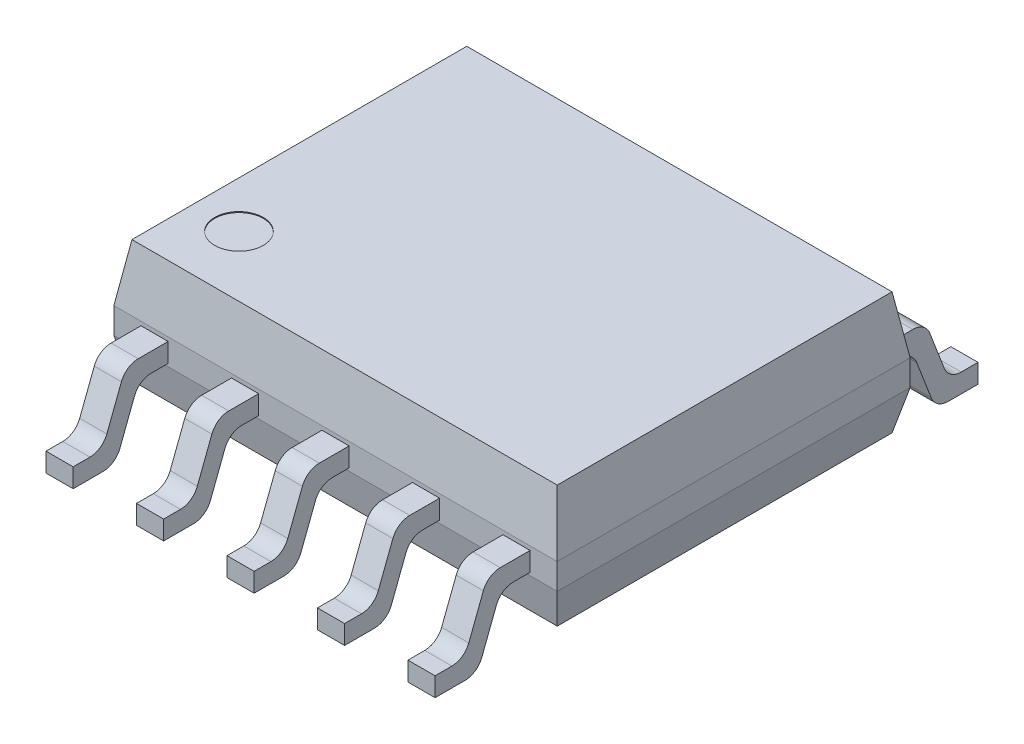
from build123d import *

# Parameters (mm, degrees)
SKETCH1_W           = 4.9
SKETCH1_H           = 3.9
BOSS_EXTRUDE1_DEPTH = 1.35
BOSS_EXTRUDE2_DEPTH = 4.9
FILLET1_R           = 0.2
SKETCH3_OUTSIDE_W   = 8.328
SKETCH3_OUTSIDE_H   = 8.378
SKETCH3_OUTSIDE_W_2 = 0.3
SKETCH3_OUTSIDE_H_2 = 1.05
CUT_EXTRUDE1_DEPTH  = 2.56
CHAMFER1_SIZE       = 0.1
CHAMFER1_SIZE2      = 0.433147587
CHAMFER2_SIZE       = 0.1
CHAMFER2_SIZE2      = 0.631375151
SKETCH4_R           = 0.268615899
CUT_EXTRUDE2_DEPTH  = 0.01


with BuildPart() as part:
    # Sketch1 → Boss-Extrude1 (new body)
    with BuildSketch(Plane(origin=(0, 0, 0), x_dir=(1, 0, 0), z_dir=(0, 1, 0))):
        Rectangle(SKETCH1_W, SKETCH1_H)
    extrude(amount=BOSS_EXTRUDE1_DEPTH)

    # Chamfer1
    chamfer1_edges = [part.edges().sort_by_distance(p)[0] for p in [
        (0, 0, -1.95),
        (2.45, 0, 0),
        (0, 0, 1.95),
        (-2.45, 0, 0),
    ]]
    chamfer1_side = [part.faces().sort_by_distance(p)[0] for p in [
        (0, 0, 0),
    ]]
    chamfer(chamfer1_edges, length=CHAMFER1_SIZE, length2=CHAMFER1_SIZE2, reference=chamfer1_side[0])

    # Chamfer2
    chamfer2_edges = [part.edges().sort_by_distance(p)[0] for p in [
        (2.45, 1.35, 0),
        (0, 1.35, -1.95),
        (-2.45, 1.35, 0),
        (0, 1.35, 1.95),
    ]]
    chamfer2_side = [part.faces().sort_by_distance(p)[0] for p in [
        (0, 1.35, 0),
    ]]
    chamfer(chamfer2_edges, length=CHAMFER2_SIZE, length2=CHAMFER2_SIZE2, reference=chamfer2_side[0])

    # Sketch4 → Cut-Extrude2 (cut)
    with BuildSketch(Plane(origin=(0, 1.35, 0), x_dir=(1, 0, 0), z_dir=(0, 1, 0))):
        with Locations((-1.836838836, -1.180555556)):
            Circle(SKETCH4_R)
    extrude(amount=-CUT_EXTRUDE2_DEPTH, mode=Mode.SUBTRACT)


with BuildPart() as body_2:
    # Sketch2 → Boss-Extrude2 (new body)
    with BuildSketch(Plane(origin=(2.45, 0, 0), x_dir=(0, 0, -1), z_dir=(1, 0, 0))):
        Polygon((-1.95, 0.465), (-2.273129751, 0.465), (-2.532616852, -0.21), (-3, -0.21), (-3, 0), (-2.676870249, 0), (-2.417383148, 0.675), (-1.95, 0.675), align=None)
    extrude(amount=-BOSS_EXTRUDE2_DEPTH)

    # Fillet1
    fillet1_edges = [body_2.edges().sort_by_distance(p)[0] for p in [
        (0, 0.465, 2.273129751),
        (0, -0.21, 2.532616852),
        (0, 0, 2.676870249),
        (0, 0.675, 2.417383148),
    ]]
    fillet(fillet1_edges, radius=FILLET1_R)

    # Sketch3 outside → Cut-Extrude1 (cut, through all)
    with BuildSketch(Plane(origin=(0, 1.35, 0), x_dir=(1, 0, 0), z_dir=(0, 1, 0))):
        with Locations((0, -0.525)):
            Rectangle(SKETCH3_OUTSIDE_W, SKETCH3_OUTSIDE_H)
        with Locations((0, -2.475)):
            Rectangle(SKETCH3_OUTSIDE_W_2, SKETCH3_OUTSIDE_H_2, mode=Mode.SUBTRACT)
        with Locations((1, -2.475)):
            Rectangle(SKETCH3_OUTSIDE_W_2, SKETCH3_OUTSIDE_H_2, mode=Mode.SUBTRACT)
        with Locations((2, -2.475)):
            Rectangle(SKETCH3_OUTSIDE_W_2, SKETCH3_OUTSIDE_H_2, mode=Mode.SUBTRACT)
        with Locations((-1, -2.475)):
            Rectangle(SKETCH3_OUTSIDE_W_2, SKETCH3_OUTSIDE_H_2, mode=Mode.SUBTRACT)
        with Locations((-2, -2.475)):
            Rectangle(SKETCH3_OUTSIDE_W_2, SKETCH3_OUTSIDE_H_2, mode=Mode.SUBTRACT)
    extrude(amount=-CUT_EXTRUDE1_DEPTH, mode=Mode.SUBTRACT)


with BuildPart() as body_3:
    # Mirror2: mirrored copy
    add(body_2.part.mirror(Plane.XY))


solid = Compound([part.part, body_2.part, body_3.part])
